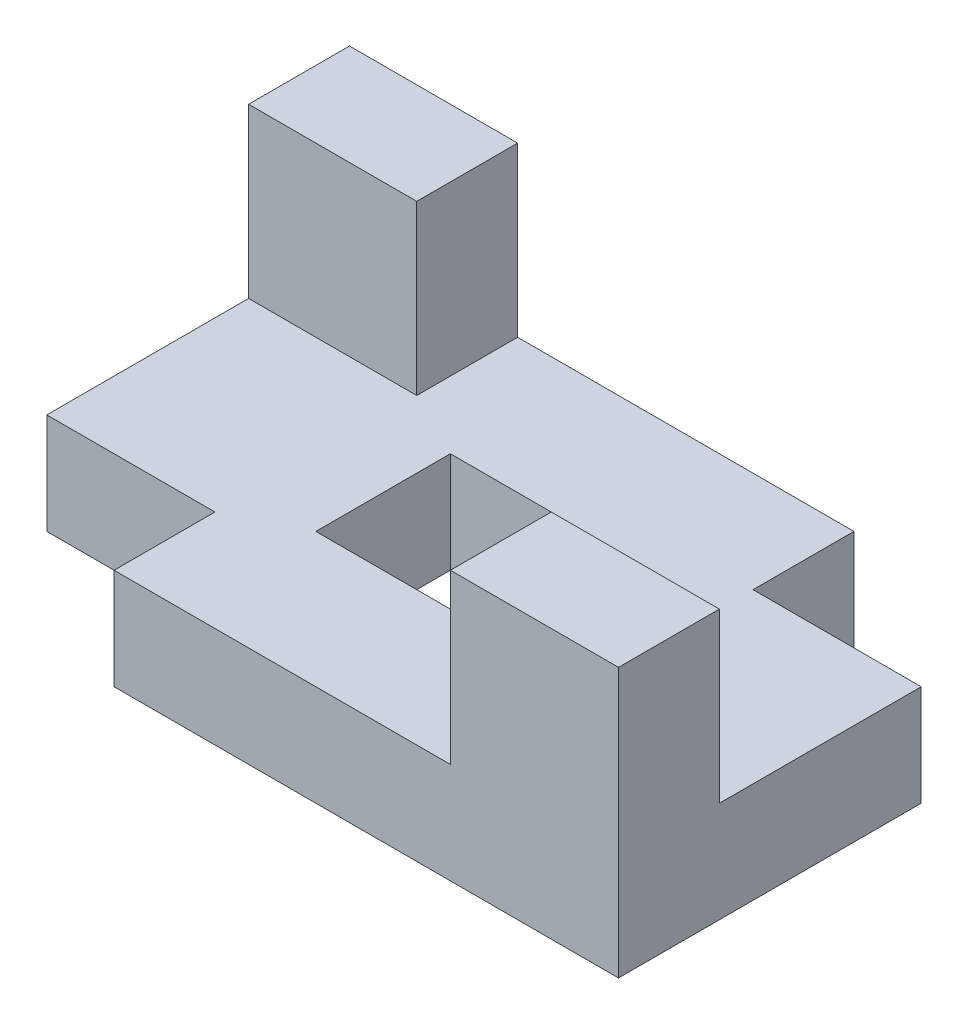
from build123d import *

# Parameters (mm, degrees)
SKETCH1_W           = 30
SKETCH1_H           = 20
BOSS_EXTRUDE1_DEPTH = 15
SKETCH1_3_W         = 25
SKETCH1_3_H         = 15
BOSS_EXTRUDE2_DEPTH = 40


with BuildPart() as part:
    # Sketch1 → Boss-Extrude1 (new body)
    with BuildSketch(Plane(origin=(0, 0, 0), x_dir=(1, 0, 0), z_dir=(0, 1, 0))):
        Polygon((-25, -15), (-25, -30), (25, -30), (25, -15), (50, -15), (50, 15), (25, 15), (25, 30), (-25, 30), (-25, 15), (-50, 15), (-50, -15), align=None)
        Rectangle(SKETCH1_W, SKETCH1_H, mode=Mode.SUBTRACT)
    extrude(amount=BOSS_EXTRUDE1_DEPTH)

    # Sketch1_3 → Boss-Extrude2 (add)
    with BuildSketch(Plane(origin=(0, 0, 0), x_dir=(1, 0, 0), z_dir=(0, 1, 0))):
        with Locations((37.5, -22.5)):
            Rectangle(SKETCH1_3_W, SKETCH1_3_H)
        with Locations((-37.5, 22.5)):
            Rectangle(SKETCH1_3_W, SKETCH1_3_H)
    extrude(amount=BOSS_EXTRUDE2_DEPTH)


solid = part.part
